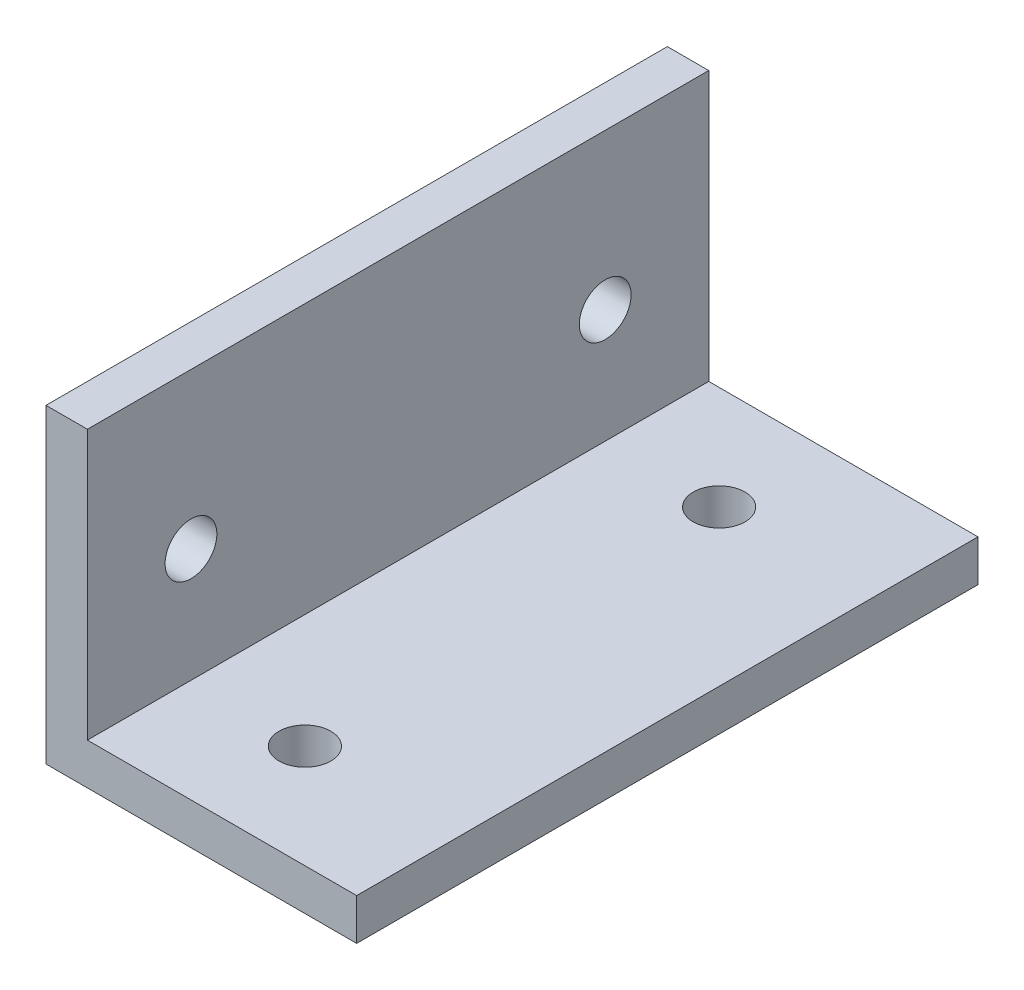
from build123d import *

# Parameters (mm, degrees)
EXTRUDE_1_DEPTH          = 30
M3X0_5_1_D               = 2.5
M3X0_5_1_DEPTH           = 8.5
M3X0_5_1_TIP             = 0.751075774
M3X0_5_1_ON_FACE_2_D     = 2.5
M3X0_5_1_ON_FACE_2_DEPTH = 8.5
M3X0_5_1_ON_FACE_2_TIP   = 0.751075774


with BuildPart() as part:
    # ｽｹｯﾁ1 → ﾎﾞｽ - 押し出し1 (new body)
    with BuildSketch(Plane.XY):
        Polygon((0, 0), (0, 15), (2, 15), (2, 2), (15, 2), (15, 0), align=None)
    extrude(amount=EXTRUDE_1_DEPTH)

    # M3x0.5 ねじ穴1
    with Locations(Plane(origin=(7.5, 0, 5), x_dir=(0, 0, -1), z_dir=(0, -1, 0))):
        with Locations((0, 0), (-20, 0)):
            Hole(M3X0_5_1_D / 2, depth=M3X0_5_1_DEPTH)
            with Locations((0, 0, -(M3X0_5_1_DEPTH + M3X0_5_1_TIP / 2))):  # 118° drill point
                Cone(0, M3X0_5_1_D / 2, M3X0_5_1_TIP, mode=Mode.SUBTRACT)

    # M3x0.5 ねじ穴1 on face 2
    with Locations(Plane(origin=(0, 7.5, 25), x_dir=(0, 0, -1), z_dir=(-1, 0, 0))):
        with Locations((0, 0), (20, 0)):
            Hole(M3X0_5_1_ON_FACE_2_D / 2, depth=M3X0_5_1_ON_FACE_2_DEPTH)
            with Locations((0, 0, -(M3X0_5_1_ON_FACE_2_DEPTH + M3X0_5_1_ON_FACE_2_TIP / 2))):  # 118° drill point
                Cone(0, M3X0_5_1_ON_FACE_2_D / 2, M3X0_5_1_ON_FACE_2_TIP, mode=Mode.SUBTRACT)


solid = part.part
